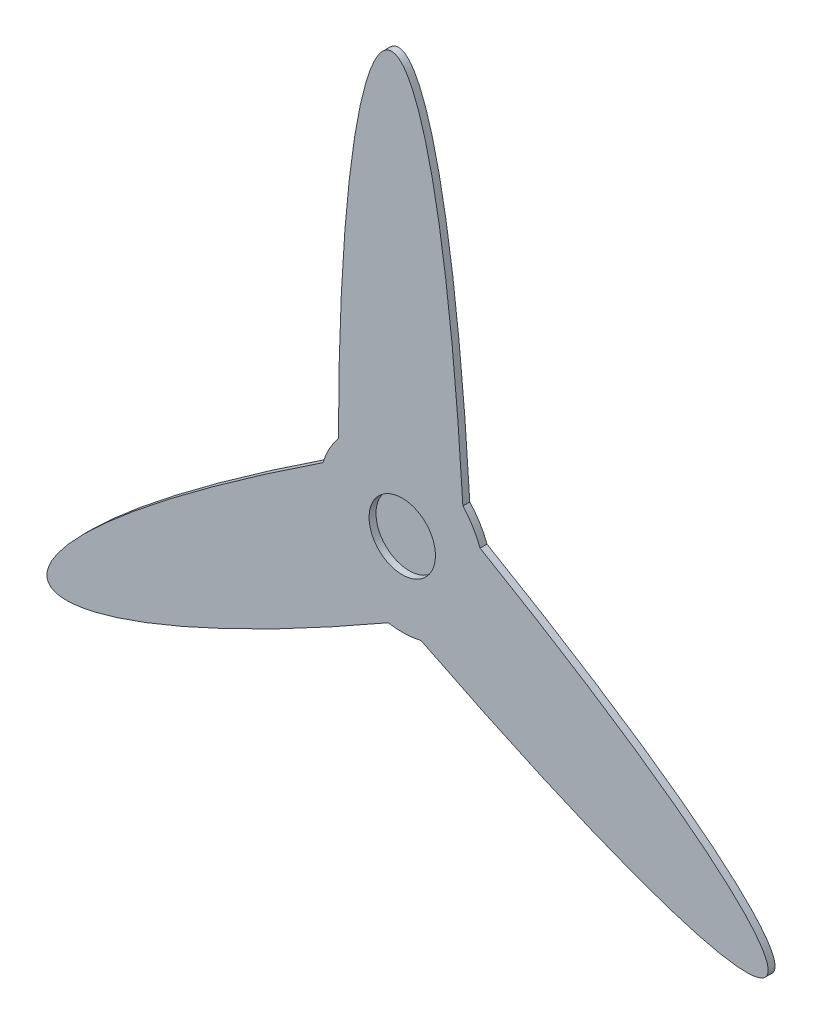
from build123d import *

# Parameters (mm, degrees)
SKETCH1_R           = 24
BOSS_EXTRUDE2_DEPTH = 5
CIRPATTERN1_COUNT   = 3
REVOLVE1_ANGLE      = 180


with BuildPart() as part:
    # Sketch1 → Boss-Extrude2 (new body)
    with BuildSketch(Plane.XY):
        with BuildLine():
            ThreePointArc((-46.162964947, 38.327283589), (1.759211062, -59.974204258), (43.837035053, 40.967235174))
            add(Edge.make_bspline(
                [(43.837035053, 40.967235174), (22.573319666, 400.135667747), (-45.629324476, 373.080153996), (-46.162964947, 38.327283589)],
                knots=[0, 0, 0, 0, 1, 1, 1, 1], degree=3))
        make_face()
        Circle(SKETCH1_R, mode=Mode.SUBTRACT)
    boss_extrude2 = extrude(amount=BOSS_EXTRUDE2_DEPTH)

    # CirPattern1: Boss-Extrude2 ×3 about axis
    cirpattern1_axis = Axis((0, 0, 5), (0, 0, 1))
    for i in range(1, CIRPATTERN1_COUNT):
        add(boss_extrude2.rotate(cirpattern1_axis, i * 360 / CIRPATTERN1_COUNT))

    # Sketch2 → Revolve1 (revolve)
    with BuildSketch(Plane.XY):
        with BuildLine():
            Line((0, 28.5), (0, -28.5))
            ThreePointArc((0, -28.5), (-28.5, 0), (0, 28.5))
        make_face()
    revolve(axis=Axis((0, 28.5, 0), (0, -1, 0)), revolution_arc=REVOLVE1_ANGLE)


solid = part.part
